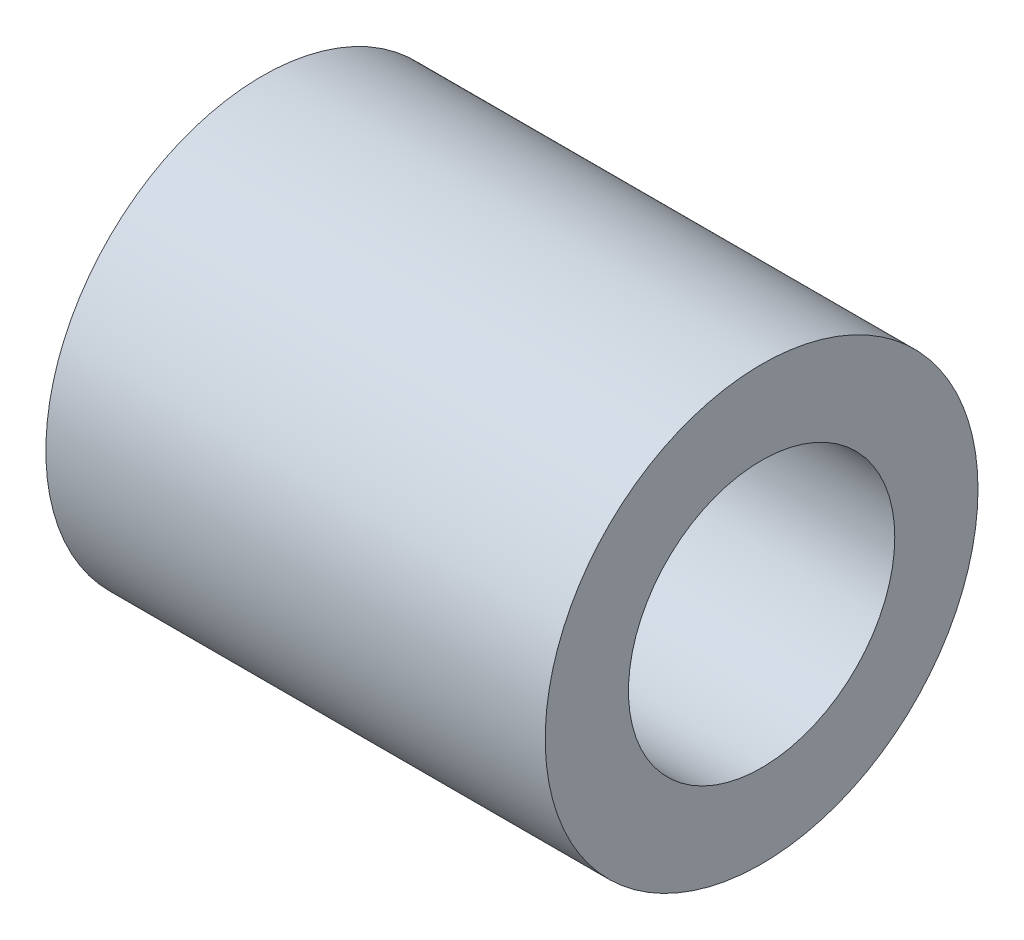
from build123d import *

# Parameters (mm, degrees)
SKETCH_1_R      = 13
SKETCH_1_R_2    = 8
EXTRUDE_1_DEPTH = 30


with BuildPart() as part:
    # 草图1 → 凸台-拉伸1 (new body)
    with BuildSketch(Plane(origin=(0, 0, 0), x_dir=(0, 0, -1), z_dir=(1, 0, 0))):
        Circle(SKETCH_1_R)
        Circle(SKETCH_1_R_2, mode=Mode.SUBTRACT)
    extrude(amount=-EXTRUDE_1_DEPTH)


solid = part.part
